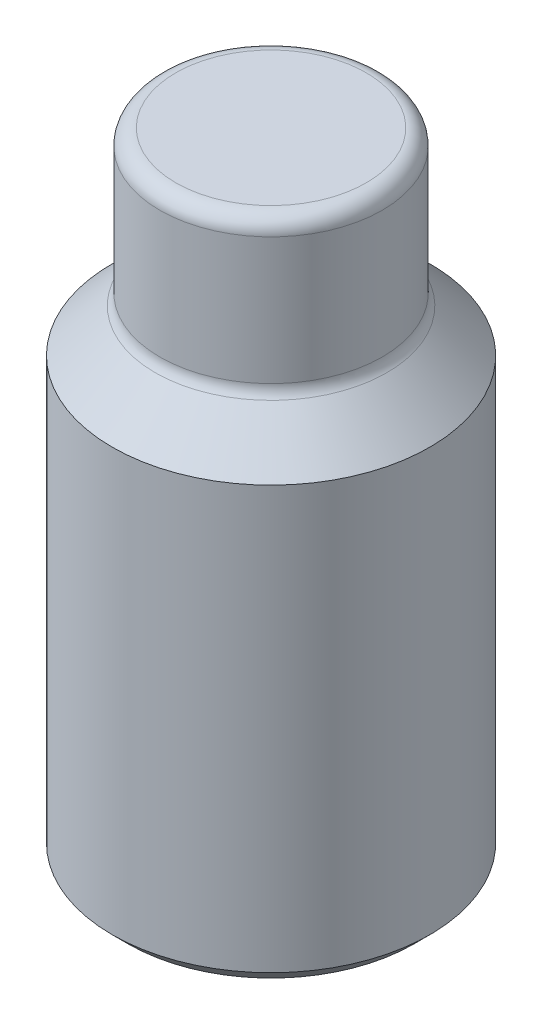
from build123d import *

# Parameters (mm, degrees)
SKETCH1_R                 = 5
BOSS_EXTRUDE1_DEPTH       = 15
SKETCH2_R                 = 3.5
BOSS_EXTRUDE2_DEPTH       = 5
FILLET1_R                 = 0.5
F_5_0MM_DOWEL_HOLE2_D     = 5
F_5_0MM_DOWEL_HOLE2_DEPTH = 6
F_5_0MM_DOWEL_HOLE2_TIP   = 1.502151548
CUT_EXTRUDE1_DEPTH        = 6
CHAMFER1_SIZE             = 0.5


with BuildPart() as part:
    # Sketch1 → Boss-Extrude1 (new body)
    with BuildSketch(Plane(origin=(0, 0, 0), x_dir=(1, 0, 0), z_dir=(0, 1, 0))):
        Circle(SKETCH1_R)
    extrude(amount=BOSS_EXTRUDE1_DEPTH)

    # Sketch2 → Boss-Extrude2 (add)
    with BuildSketch(Plane(origin=(0, 15, 0), x_dir=(1, 0, 0), z_dir=(0, 1, 0))):
        Circle(SKETCH2_R)
    extrude(amount=BOSS_EXTRUDE2_DEPTH)

    # Fillet1
    fillet1_edges = [part.edges().sort_by_distance(p)[0] for p in [
        (-3.5, 15, 0),
        (-3.5, 20, 0),
    ]]
    fillet(fillet1_edges, radius=FILLET1_R)

    # Sketch3 → Cut-Revolve1 (revolve, cut)
    with BuildSketch(Plane.XY):
        Polygon((-5, 13.792893219), (-3.646446609, 15.146446609), (-5, 15), align=None)
    revolve(axis=Axis((0, 20, 0), (0, -1, 0)), mode=Mode.SUBTRACT)

    # Ø5.0mm Dowel Hole2
    with Locations(Plane(origin=(0, 0, 0), x_dir=(-1, 0, 0), z_dir=(0, -1, 0))):
        with Locations((0, 0)):
            Hole(F_5_0MM_DOWEL_HOLE2_D / 2, depth=F_5_0MM_DOWEL_HOLE2_DEPTH)
            with Locations((0, 0, -(F_5_0MM_DOWEL_HOLE2_DEPTH + F_5_0MM_DOWEL_HOLE2_TIP / 2))):  # 118° drill point
                Cone(0, F_5_0MM_DOWEL_HOLE2_D / 2, F_5_0MM_DOWEL_HOLE2_TIP, mode=Mode.SUBTRACT)

    # Sketch4 → Cut-Extrude1 (cut)
    with BuildSketch(Plane.XZ):
        Polygon((2.886751346, 0), (1.443375673, 2.5), (-1.443375673, 2.5), (-2.886751346, 0), (-1.443375673, -2.5), (1.443375673, -2.5), align=None)
    extrude(amount=-CUT_EXTRUDE1_DEPTH, mode=Mode.SUBTRACT)

    # Chamfer1
    chamfer1_edges = [part.edges().sort_by_distance(p)[0] for p in [
        (-5, 0, 0),
    ]]
    chamfer(chamfer1_edges, length=CHAMFER1_SIZE)


solid = part.part
